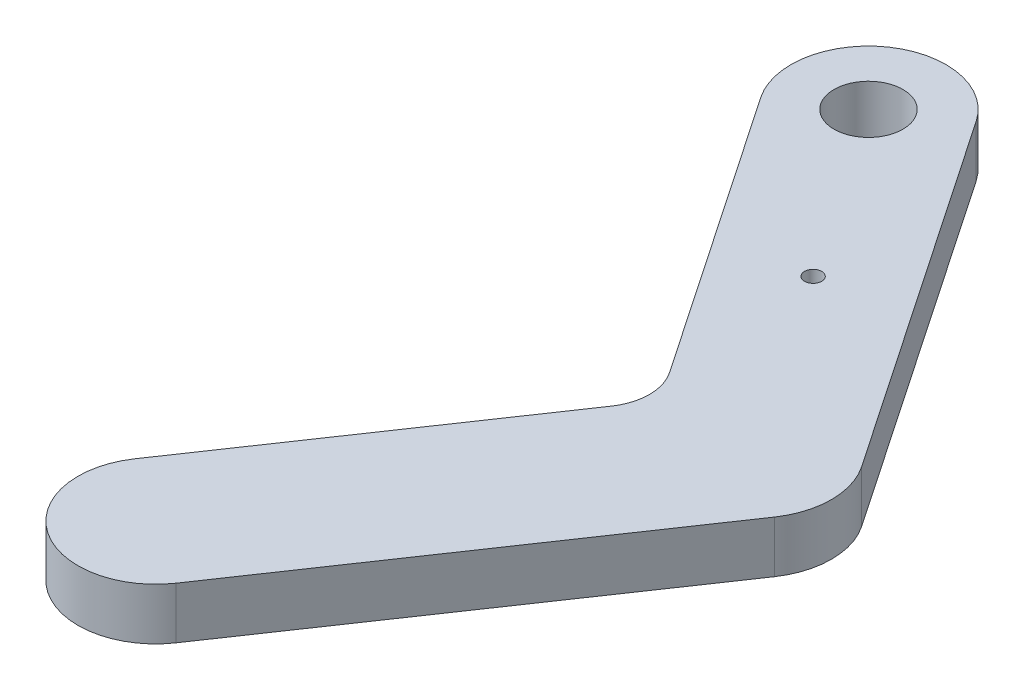
from build123d import *

# Parameters (mm, degrees)
SKETCH1_R           = 2
SKETCH1_R_2         = 0.5
BOSS_EXTRUDE1_DEPTH = 3


with BuildPart() as part:
    # Sketch1 → Boss-Extrude1 (new body)
    with BuildSketch(Plane(origin=(0, 0, 0), x_dir=(1, 0, 0), z_dir=(0, 1, 0))):
        with BuildLine():
            Line((8.814704054, 24.438023166), (22.853686429, 3.752110716))
            ThreePointArc((22.853686429, 3.752110716), (23.630222188, 1.225093889), (22.853686429, -1.301922939))
            Line((22.853686429, -1.301922939), (8.814704054, -21.987835389))
            ThreePointArc((8.814704054, -21.987835389), (2.564222985, -23.184282802), (1.367775572, -16.933801734))
            Line((1.367775572, -16.933801734), (12.548391994, -0.459583996))
            ThreePointArc((12.548391994, -0.459583996), (13.0660825, 1.225093889), (12.548391994, 2.909771774))
            Line((12.548391994, 2.909771774), (1.367775572, 19.383989511))
            ThreePointArc((1.367775572, 19.383989511), (2.564222985, 25.634470579), (8.814704054, 24.438023166))
        make_face()
        with Locations((5.091239813, 21.911006338)):
            Circle(SKETCH1_R, mode=Mode.SUBTRACT)
        with Locations((11.877683893, 11.91143626)):
            Circle(SKETCH1_R_2, mode=Mode.SUBTRACT)
    extrude(amount=BOSS_EXTRUDE1_DEPTH)


solid = part.part
